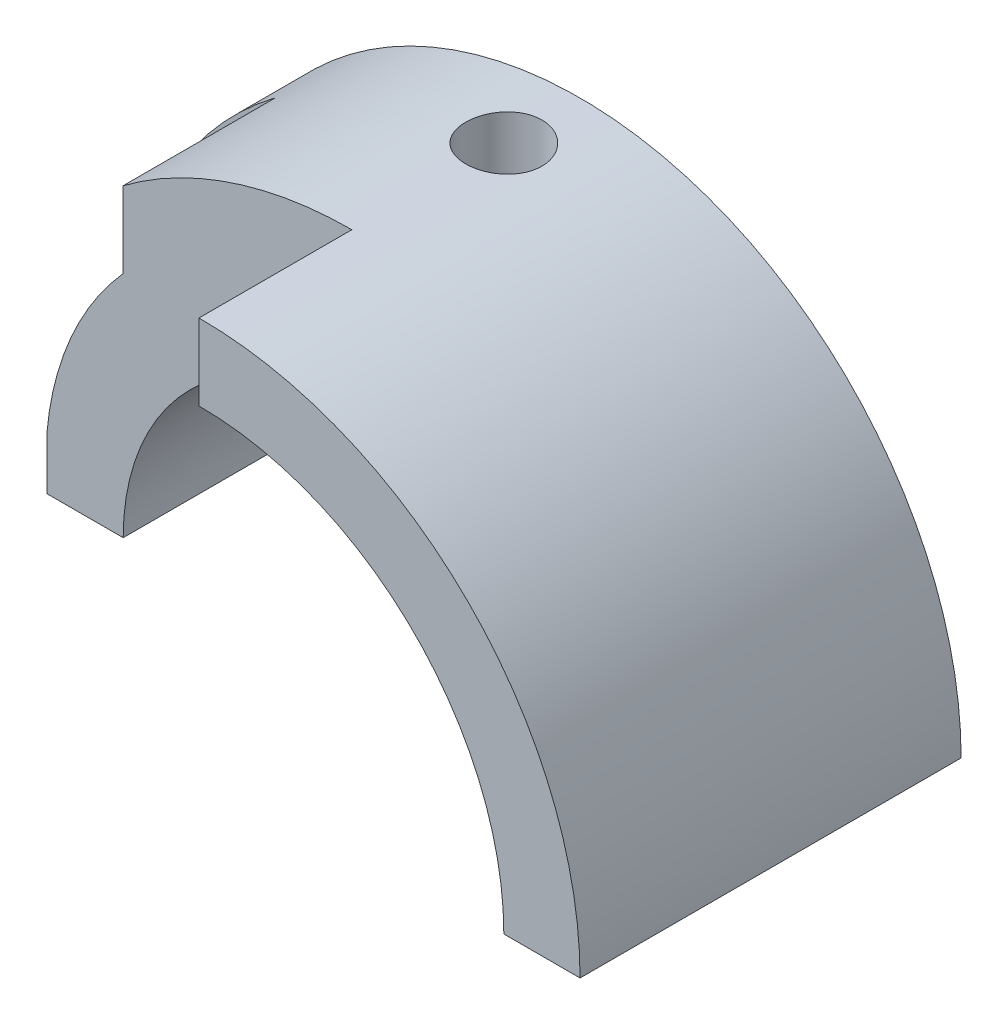
from build123d import *

# Parameters (mm, degrees)
BOSS_EXTRUDE1_DEPTH = 5
SKETCH2_R           = 0.5
CUT_EXTRUDE1_DEPTH  = 5
CUT_EXTRUDE2_DEPTH  = 1
CUT_EXTRUDE3_DEPTH  = 2


with BuildPart() as part:
    # Sketch1 → Boss-Extrude1 (new body)
    with BuildSketch(Plane.XY):
        with BuildLine():
            Line((-5, 0), (-3, 0))
            ThreePointArc((-3, 0), (0, 3), (3, 0))
            Line((3, 0), (5, 0))
            ThreePointArc((5, 0), (0, 5), (-5, 0))
        make_face()
    extrude(amount=BOSS_EXTRUDE1_DEPTH)

    # Sketch2 → Cut-Extrude1 (cut)
    with BuildSketch(Plane(origin=(0, 0, 0), x_dir=(1, 0, 0), z_dir=(0, 1, 0))):
        with Locations((0, -1)):
            Circle(SKETCH2_R)
        Polygon((-5, -1), (-4.001262059, -1), (-4.001262059, -1.997514784), (-4.001262059, -2.994544778), (0, -2.994544778), (0, -5), (-5, -5), align=None)
    extrude(amount=CUT_EXTRUDE1_DEPTH, mode=Mode.SUBTRACT)

    # Sketch3 → Cut-Extrude2 (cut)
    with BuildSketch(Plane.XY.offset(5)):
        with BuildLine():
            Line((0, 4), (0, 0))
            Line((0, 0), (4, 0))
            ThreePointArc((4, 0), (2.828427125, 2.828427125), (0, 4))
        make_face()
    extrude(amount=-CUT_EXTRUDE2_DEPTH, mode=Mode.SUBTRACT)

    # Sketch4 → Cut-Extrude3 (cut)
    with BuildSketch(Plane.XY.offset(2.994544778)):
        with BuildLine():
            Line((-3.001262059, 3), (-3.001262059, 3.999053144))
            ThreePointArc((-3.001262059, 3.999053144), (-4.472488697, 2.235362354), (-5, 0))
            Line((-5, 0), (-4.001262059, 0))
            ThreePointArc((-4.001262059, 0), (-3.811157575, 1.603298505), (-3.001262059, 3))
        make_face()
    extrude(amount=-CUT_EXTRUDE3_DEPTH, mode=Mode.SUBTRACT)


solid = part.part
